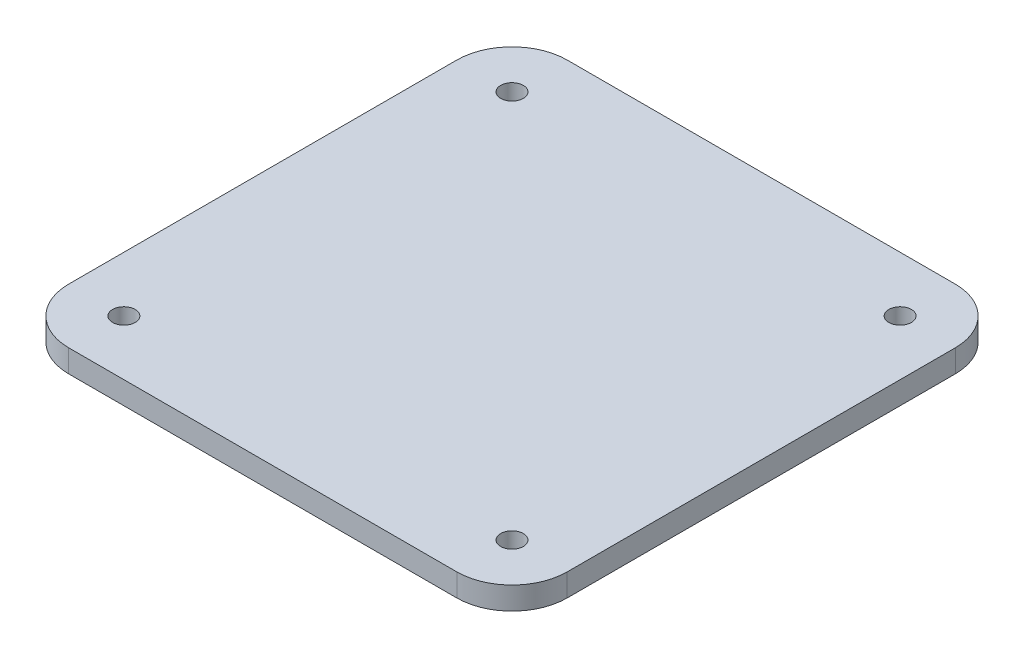
from build123d import *

# Parameters (mm, degrees)
SALIENTE_EXTRUIR1_DEPTH = 12.7
CROQUIS2_R              = 6.35
CORTAR_EXTRUIR1_DEPTH   = 13.7


with BuildPart() as part:
    # Croquis1 → Saliente-Extruir1 (new body)
    with BuildSketch(Plane(origin=(0, 0, 0), x_dir=(1, 0, 0), z_dir=(0, 1, 0))):
        with BuildLine():
            Line((-109, -140), (109, -140))
            ThreePointArc((109, -140), (130.920310217, -130.920310217), (140, -109))
            Line((140, -109), (140, 109))
            ThreePointArc((140, 109), (130.920310217, 130.920310217), (109, 140))
            Line((109, 140), (-109, 140))
            ThreePointArc((-109, 140), (-130.920310217, 130.920310217), (-140, 109))
            Line((-140, 109), (-140, -109))
            ThreePointArc((-140, -109), (-130.920310217, -130.920310217), (-109, -140))
        make_face()
    extrude(amount=SALIENTE_EXTRUIR1_DEPTH)

    # Croquis2 → Cortar-Extruir1 (cut, through all)
    with BuildSketch(Plane(origin=(0, 12.7, 0), x_dir=(1, 0, 0), z_dir=(0, 1, 0))):
        with Locations((109, 109)):
            Circle(CROQUIS2_R)
        with Locations((109, -109)):
            Circle(CROQUIS2_R)
        with Locations((-109, -109)):
            Circle(CROQUIS2_R)
        with Locations((-109, 109)):
            Circle(CROQUIS2_R)
    extrude(amount=-CORTAR_EXTRUIR1_DEPTH, mode=Mode.SUBTRACT)


solid = part.part
